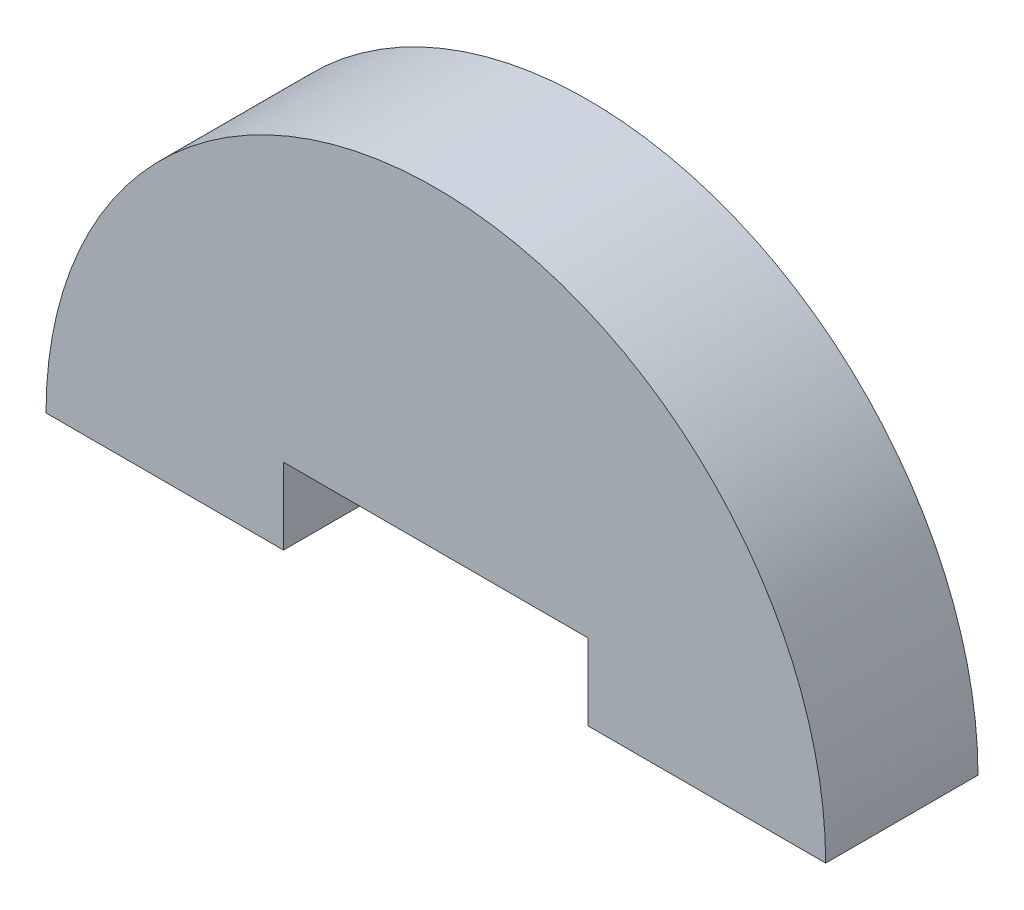
from build123d import *

# Parameters (mm, degrees)
BOSS_EXTRUDE1_DEPTH = 6


with BuildPart() as part:
    # Model → Boss-Extrude1 (new body)
    with BuildSketch(Plane.XY):
        with BuildLine():
            Line((3516.865585936, 1303.546393682), (3516.865585936, 1300.546393682))
            Line((3516.865585936, 1300.546393682), (3526.222728793, 1300.546393682))
            ThreePointArc((3526.222728793, 1300.546393682), (3510.865585936, 1315.903536539), (3495.508443079, 1300.546393682))
            Line((3495.508443079, 1300.546393682), (3504.865585936, 1300.546393682))
            Line((3504.865585936, 1300.546393682), (3504.865585936, 1303.546393682))
            Line((3504.865585936, 1303.546393682), (3516.865585936, 1303.546393682))
        make_face()
    extrude(amount=BOSS_EXTRUDE1_DEPTH)


solid = part.part
